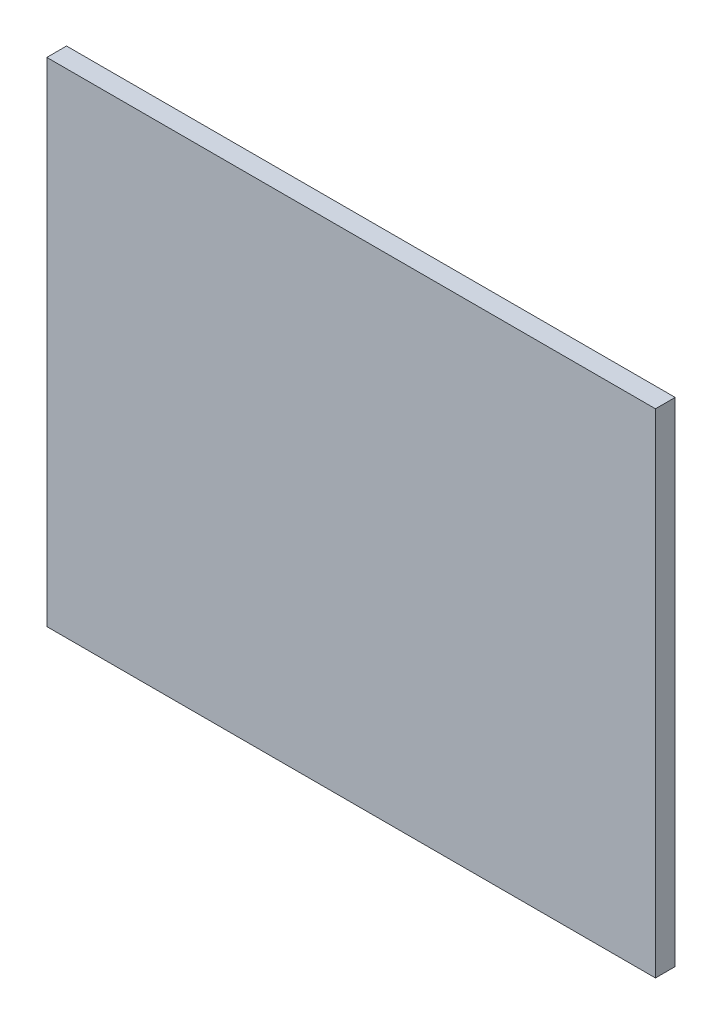
from build123d import *

# Parameters (mm, degrees)
SKETCH2_W           = 46.3
SKETCH2_H           = 37.5
BOSS_EXTRUDE1_DEPTH = 1.5


with BuildPart() as part:
    # Sketch2 → Boss-Extrude1 (new body)
    with BuildSketch(Plane.XY):
        with Locations((3.861710835, -0.442362559)):
            Rectangle(SKETCH2_W, SKETCH2_H)
    extrude(amount=BOSS_EXTRUDE1_DEPTH)


solid = part.part
